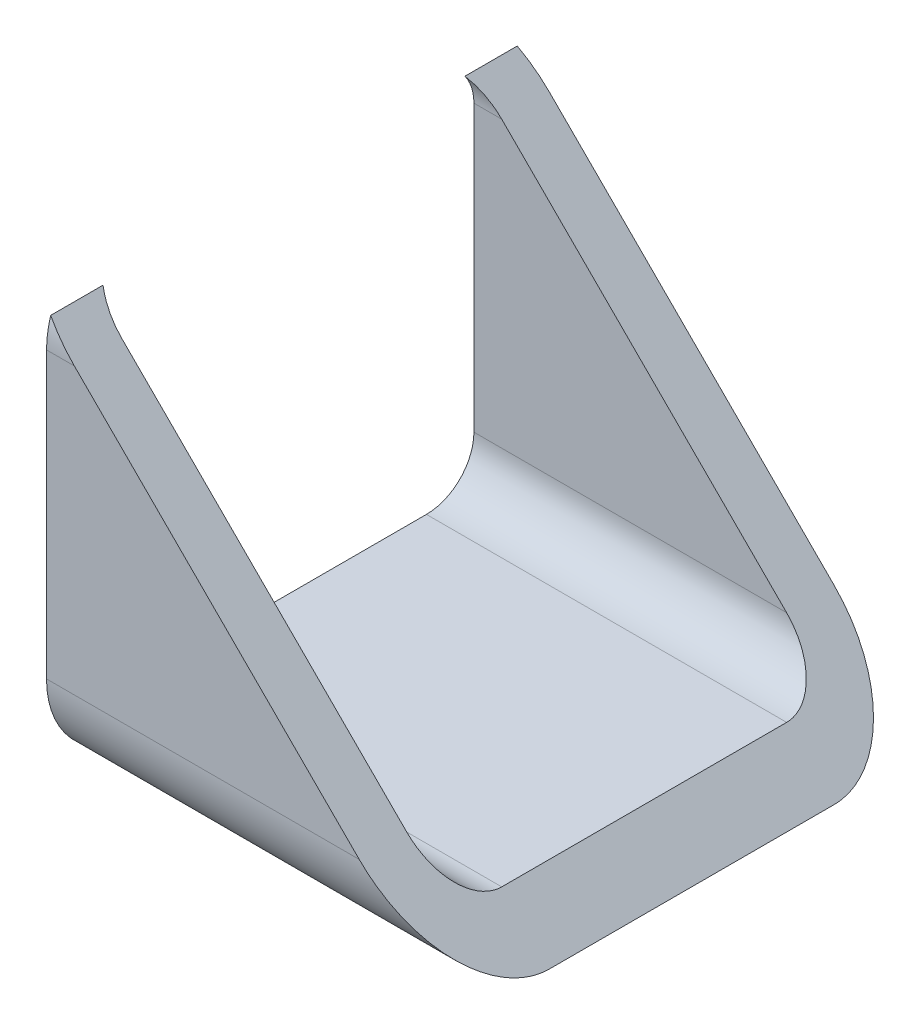
from build123d import *

# Parameters (mm, degrees)
TUBO_CUADRADO_40_X_40_X_4_1_DEPTH = 40
EXTRUDE1_REACH                    = 62


with BuildPart() as part:
    # Sketch6 → Tubo cuadrado 40 X 40 X 4(1) (new body)
    with BuildSketch(Plane(origin=(0, 0, 0), x_dir=(0, 0, -1), z_dir=(1, 0, 0))):
        with BuildLine():
            Line((-12, -20), (12, -20))
            ThreePointArc((12, -20), (17.656854249, -17.656854249), (20, -12))
            Line((20, -12), (20, 12))
            ThreePointArc((20, 12), (17.656854249, 17.656854249), (12, 20))
            Line((12, 20), (-12, 20))
            ThreePointArc((-12, 20), (-17.656854249, 17.656854249), (-20, 12))
            Line((-20, 12), (-20, -12))
            ThreePointArc((-20, -12), (-17.656854249, -17.656854249), (-12, -20))
        make_face()
        with BuildLine():
            Line((-12, -16), (12, -16))
            ThreePointArc((12, -16), (14.828427125, -14.828427125), (16, -12))
            Line((16, -12), (16, 12))
            ThreePointArc((16, 12), (14.828427125, 14.828427125), (12, 16))
            Line((12, 16), (-12, 16))
            ThreePointArc((-12, 16), (-14.828427125, 14.828427125), (-16, 12))
            Line((-16, 12), (-16, -12))
            ThreePointArc((-16, -12), (-14.828427125, -14.828427125), (-12, -16))
        make_face(mode=Mode.SUBTRACT)
    extrude(amount=TUBO_CUADRADO_40_X_40_X_4_1_DEPTH)

    # Sketch2 → Extrude1 (cut, up to next)
    with BuildSketch(Plane.XY.offset(20), mode=Mode.PRIVATE) as extrude1_sk1:
        Polygon((-9.656854249, 24), (44, -29.656854249), (44, 24), align=None)
    extrude1_tool1 = extrude(extrude1_sk1.sketch, amount=-EXTRUDE1_REACH, mode=Mode.PRIVATE) & part.part
    add(extrude1_tool1.solids().sort_by_distance((26.114382, 6.114382, 20))[0], mode=Mode.SUBTRACT)


solid = part.part
